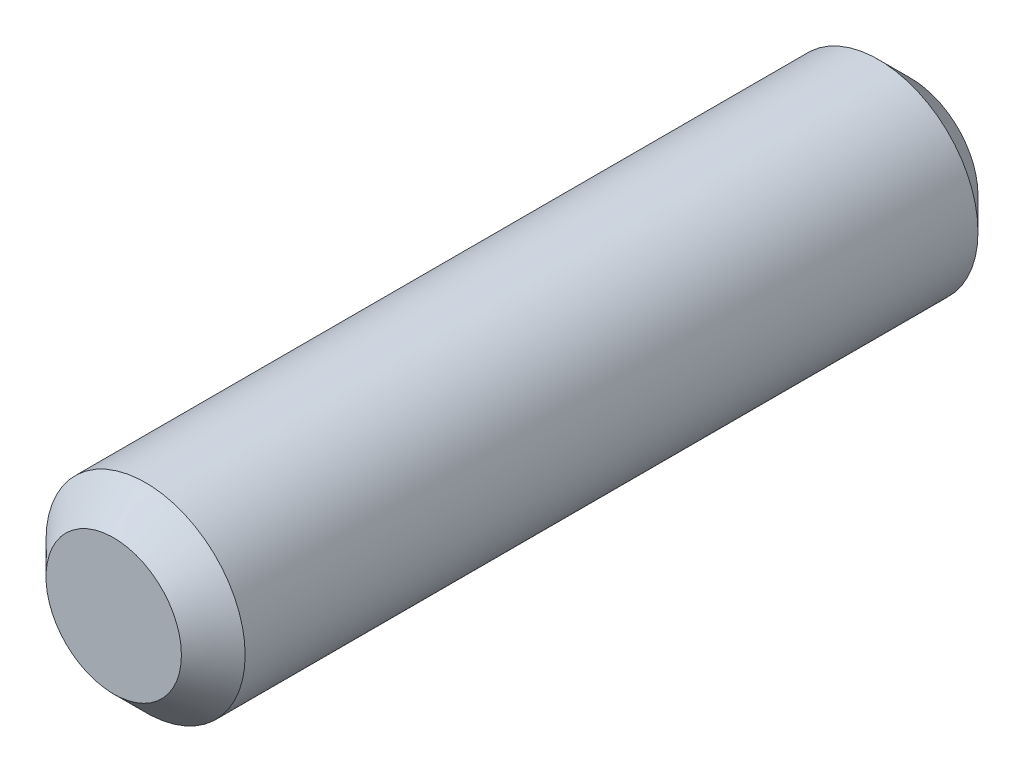
from build123d import *

# Parameters (mm, degrees)
SKETCH1_R           = 1.5875
BOSS_EXTRUDE1_DEPTH = 12.7
CHAMFER1_SIZE       = 0.508


with BuildPart() as part:
    # Sketch1 → Boss-Extrude1 (new body)
    with BuildSketch(Plane.XY):
        Circle(SKETCH1_R)
    extrude(amount=BOSS_EXTRUDE1_DEPTH)

    # Chamfer1
    chamfer1_edges = [part.edges().sort_by_distance(p)[0] for p in [
        (-1.5875, 0, 0),
        (-1.5875, 0, 12.7),
    ]]
    chamfer(chamfer1_edges, length=CHAMFER1_SIZE)


solid = part.part
